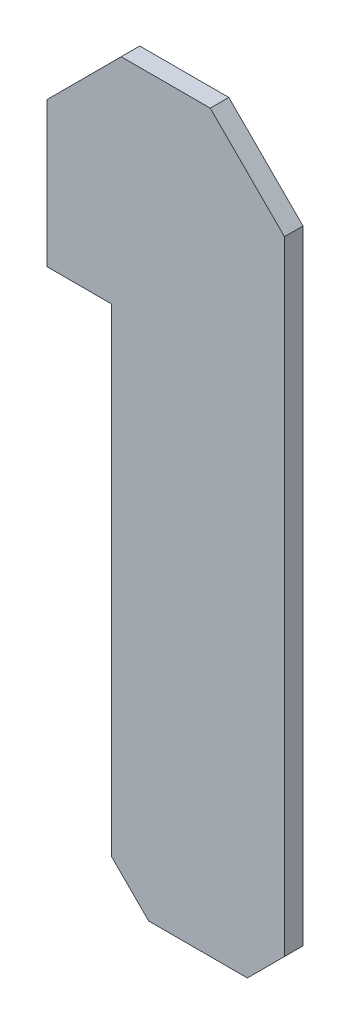
from build123d import *

# Parameters (mm, degrees)
BOSS_EXTRUDE1_DEPTH = 0.5


with BuildPart() as part:
    # Sketch1 → Boss-Extrude1 (new body)
    with BuildSketch(Plane.XY):
        Polygon((1.74227915, -13.65), (2.74227915, -14.65), (5.4, -14.65), (6.4, -13.65), (6.4, 0.1), (6.4, 3.15), (4.4, 5.15), (2, 5.15), (0, 3.15), (0, 0.1), (0, -0.75), (1.74227915, -0.75), align=None)
    extrude(amount=BOSS_EXTRUDE1_DEPTH)


solid = part.part
